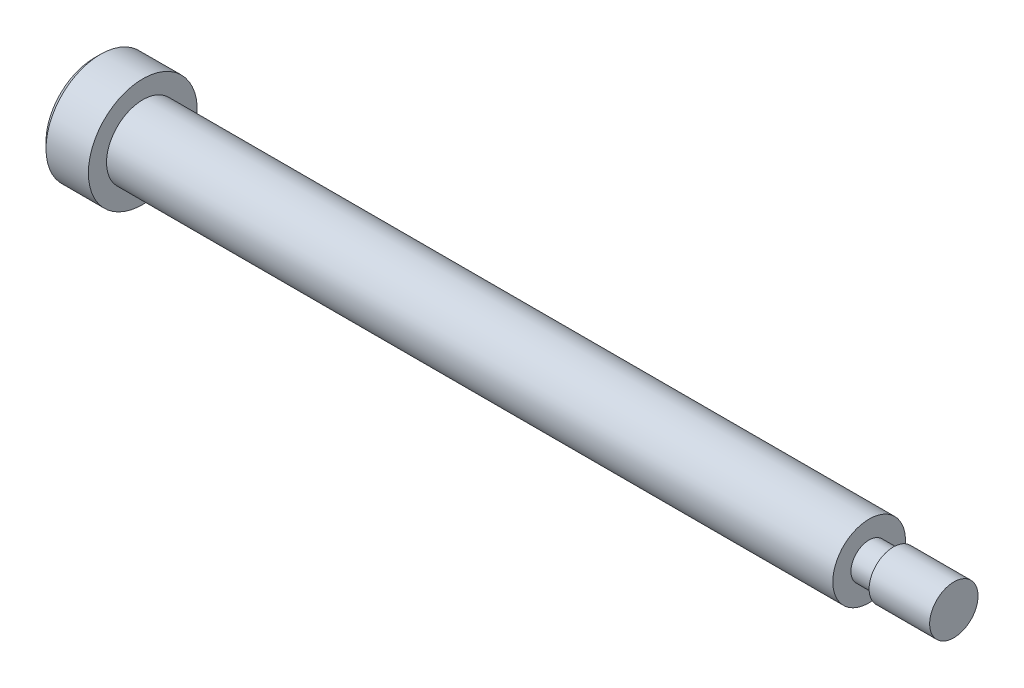
from build123d import *

# Parameters (mm, degrees)
CHAMFER2_SIZE      = 0.5
CUT_EXTRUDE1_DEPTH = 2


with BuildPart() as part:
    # Sketch1 → Revolve1 (revolve)
    with BuildSketch(Plane.XY):
        Polygon((0, 3), (60, 3), (60, 1.5), (62, 1.5), (62, 2), (67, 2), (67, 0), (-4, 0), (-4, 4.5), (0, 4.5), align=None)
    revolve(axis=Axis((-15.448246648, 0, 0), (1, 0, 0)))

    # Chamfer2
    chamfer2_edges = [part.edges().sort_by_distance(p)[0] for p in [
        (-4, -4.5, 0),
    ]]
    chamfer(chamfer2_edges, length=CHAMFER2_SIZE)

    # Sketch2 → Cut-Extrude1 (cut)
    with BuildSketch(Plane.ZY.offset(4)):
        Polygon((0, 1.732050808), (-1.5, 0.866025404), (-1.5, -0.866025404), (0, -1.732050808), (1.5, -0.866025404), (1.5, 0.866025404), align=None)
    extrude(amount=-CUT_EXTRUDE1_DEPTH, mode=Mode.SUBTRACT)


solid = part.part
